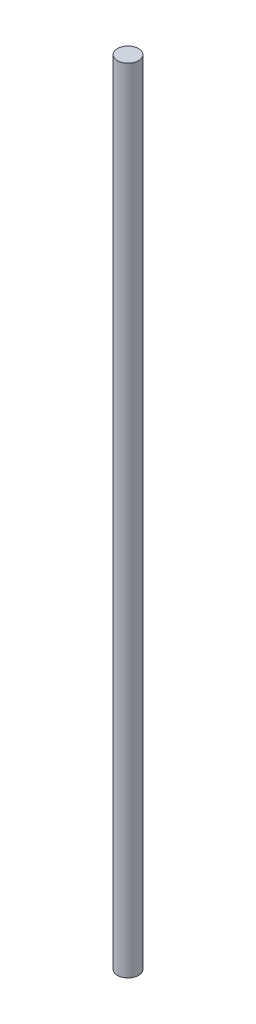
from build123d import *

# Parameters (mm, degrees)
CROQUIS1_R              = 4
SALIENTE_EXTRUIR1_DEPTH = 300


with BuildPart() as part:
    # Croquis1 → Saliente-Extruir1 (new body)
    with BuildSketch(Plane(origin=(0, 0, 0), x_dir=(1, 0, 0), z_dir=(0, 1, 0))):
        Circle(CROQUIS1_R)
    extrude(amount=SALIENTE_EXTRUIR1_DEPTH)


solid = part.part
